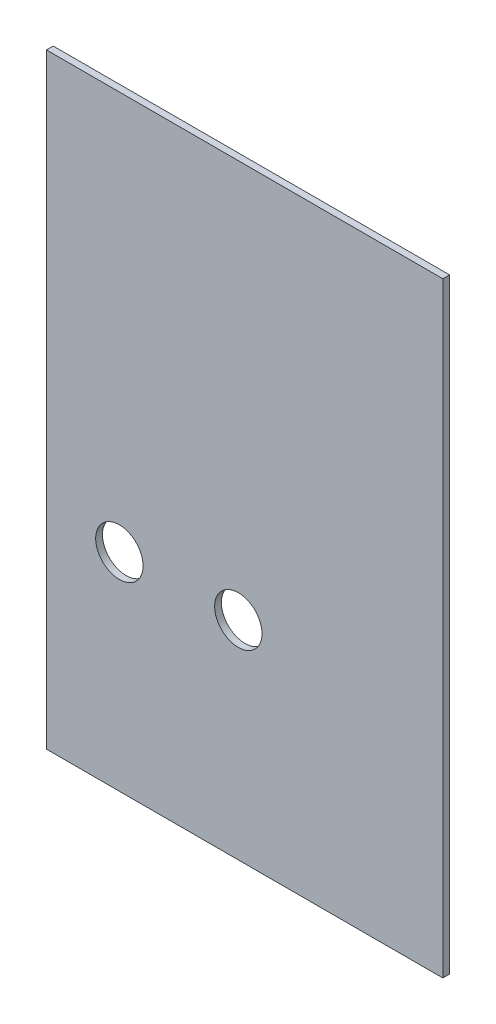
from build123d import *

# Parameters (mm, degrees)
SKETCH1_W           = 186.616953842
SKETCH1_H           = 285.110155161
BOSS_EXTRUDE1_DEPTH = 1.5875
SKETCH2_R           = 11.15
CUT_EXTRUDE1_DEPTH  = 4.175


with BuildPart() as part:
    # Sketch1 → Boss-Extrude1 (new body, symmetric)
    with BuildSketch(Plane.XY):
        with Locations((93.308476921, 142.555077581)):
            Rectangle(SKETCH1_W, SKETCH1_H)
    extrude(amount=BOSS_EXTRUDE1_DEPTH, both=True)

    # Sketch2 → Cut-Extrude1 (cut, through all)
    with BuildSketch(Plane.XY.offset(1.5875)):
        with Locations((90.33901258, 97.817400981)):
            Circle(SKETCH2_R)
        with Locations((34.339946259, 97.494026403)):
            Circle(SKETCH2_R)
    extrude(amount=-CUT_EXTRUDE1_DEPTH, mode=Mode.SUBTRACT)


solid = part.part
